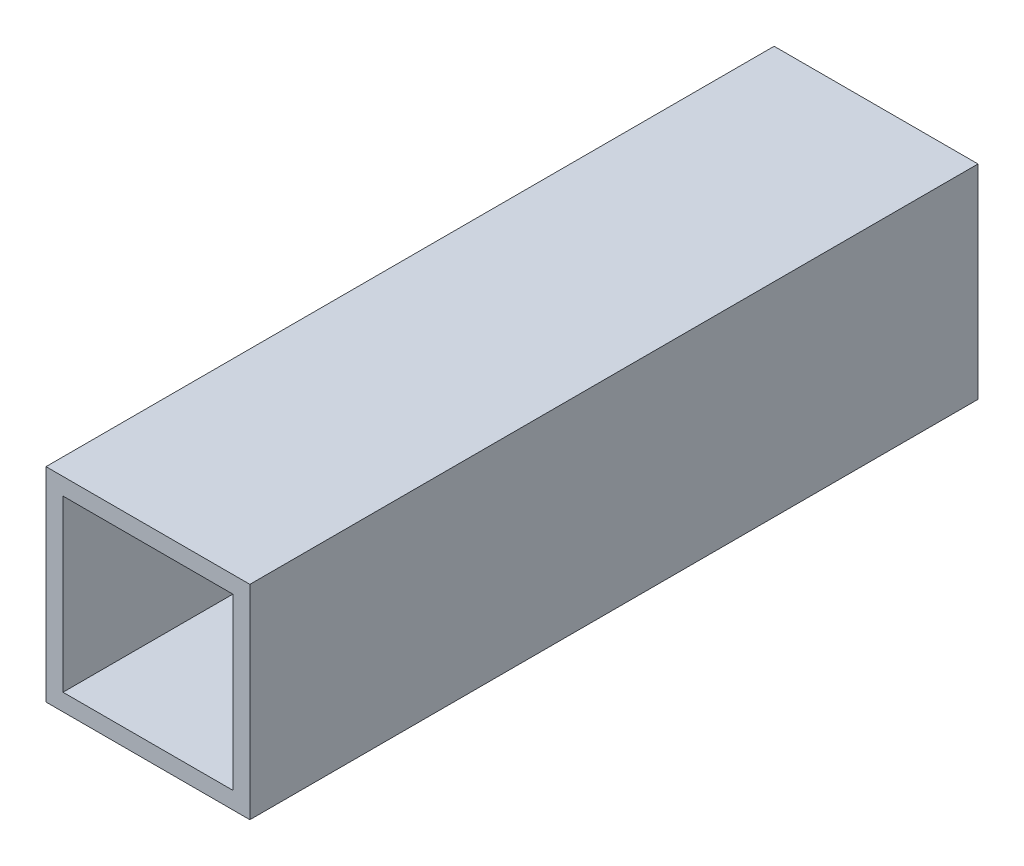
from build123d import *

# Parameters (mm, degrees)
SKIZZE1_W                       = 12.6
SKIZZE1_H                       = 12.6
AUFSATZ_LINEAR_AUSTRAGEN1_DEPTH = 45
SKIZZE2_W                       = 10.5
SKIZZE2_H                       = 10.5
SCHNITT_LINEAR_AUSTRAGEN1_DEPTH = 43.5


with BuildPart() as part:
    # Skizze1 → Aufsatz-Linear austragen1 (new body)
    with BuildSketch(Plane.XY):
        Rectangle(SKIZZE1_W, SKIZZE1_H)
    extrude(amount=AUFSATZ_LINEAR_AUSTRAGEN1_DEPTH)

    # Skizze2 → Schnitt-Linear austragen1 (cut)
    with BuildSketch(Plane.XY.offset(45)):
        Rectangle(SKIZZE2_W, SKIZZE2_H)
    extrude(amount=-SCHNITT_LINEAR_AUSTRAGEN1_DEPTH, mode=Mode.SUBTRACT)


solid = part.part
